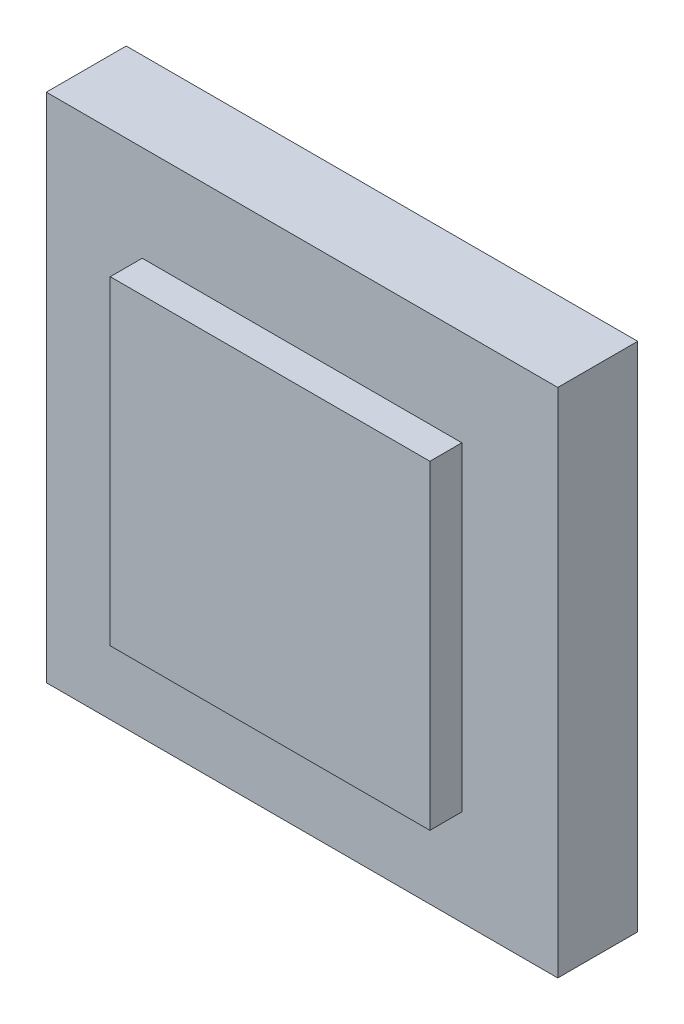
from build123d import *

# Parameters (mm, degrees)
SKETCH1_W           = 406.4
SKETCH1_H           = 406.4
BOSS_EXTRUDE1_DEPTH = 63.5
SKETCH2_W           = 254
SKETCH2_H           = 254
BOSS_EXTRUDE2_DEPTH = 25.4


with BuildPart() as part:
    # Sketch1 → Boss-Extrude1 (new body)
    with BuildSketch(Plane.XY):
        Rectangle(SKETCH1_W, SKETCH1_H)
    extrude(amount=BOSS_EXTRUDE1_DEPTH)

    # Sketch2 → Boss-Extrude2 (add)
    with BuildSketch(Plane.XY.offset(63.5)):
        Rectangle(SKETCH2_W, SKETCH2_H)
    extrude(amount=BOSS_EXTRUDE2_DEPTH)


solid = part.part
